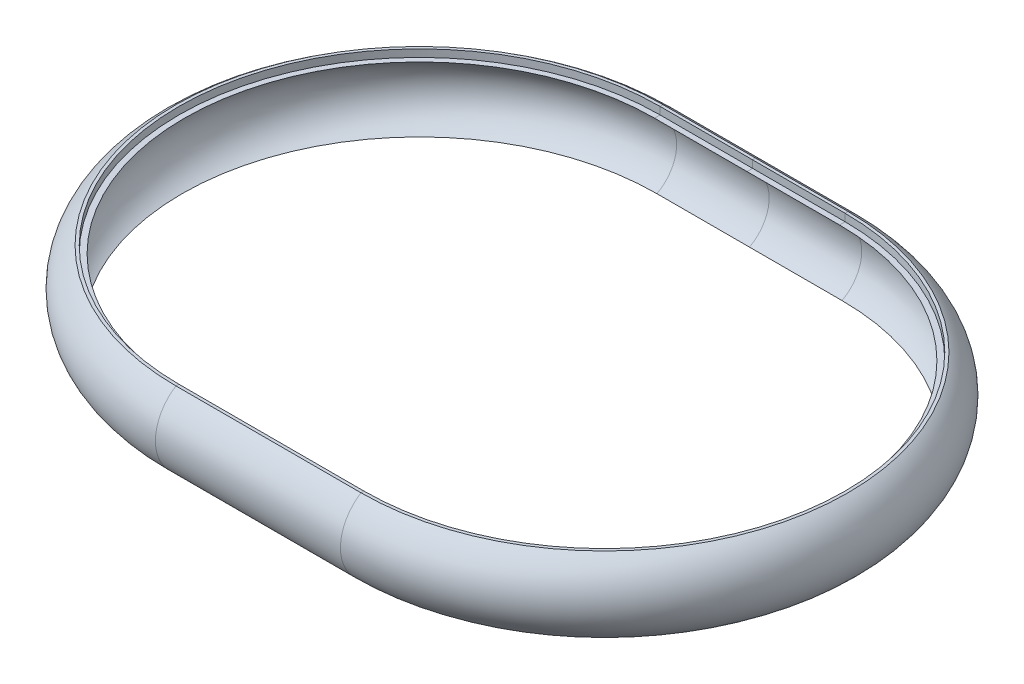
from build123d import *


with BuildPart() as part:
    # Sweep1: sweep along a path in Sketch3
    with BuildLine(Plane(origin=(0, 6.039803803, 0), x_dir=(1, 0, 0), z_dir=(0, 1, 0))) as sweep1_path:
        Line((-25, 130), (25, 130))
        ThreePointArc((25, 130), (90, 65), (25, 0))
        Line((25, 0), (-25, 0))
        ThreePointArc((-25, 0), (-90, 65), (-25, 130))
    # Sketch1 → Sweep1 (sweep)
    with BuildSketch(Plane(origin=(0, 0, 0), x_dir=(0, 0, -1), z_dir=(1, 0, 0))):
        with BuildLine():
            Line((130.8, 8.039803803), (130, 8.039803803))
            Line((130, 8.039803803), (130, 6.039803803))
            Line((130, 6.039803803), (128.5, 6.039803803))
            ThreePointArc((128.5, 6.039803803), (134.474601817, -2.75615457), (129.150095427, -11.960196197))
            Line((129.150095427, -11.960196197), (131.150095427, -11.960196197))
            ThreePointArc((131.150095427, -11.960196197), (136.343285843, -1.866226416), (130.8, 8.039803803))
        make_face()
    sweep(path=sweep1_path.line)


solid = part.part
